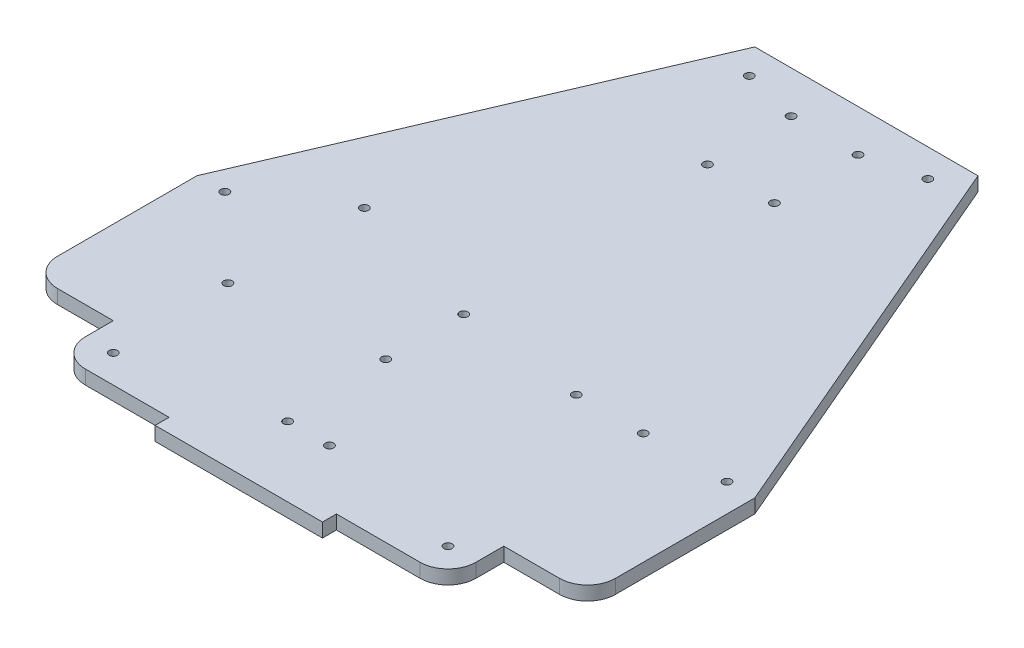
from build123d import *

# Parameters (mm, degrees)
BOSS_EXTRUDE1_DEPTH = 5
SKETCH3_R           = 1.5
CUT_EXTRUDE2_DEPTH  = 6
SKETCH6_R           = 1.5
CUT_EXTRUDE4_DEPTH  = 6
SKETCH8_R           = 1.5
CUT_EXTRUDE5_DEPTH  = 10
SKETCH9_R           = 1.5
CUT_EXTRUDE6_DEPTH  = 10


with BuildPart() as part:
    # Sketch1 → Boss-Extrude1 (new body)
    with BuildSketch(Plane(origin=(0, 0, 0), x_dir=(1, 0, 0), z_dir=(0, 1, 0))):
        with BuildLine():
            Line((100, -40), (100, 10))
            Line((100, 10), (40, 150))
            Line((40, 150), (-40, 150))
            Line((-40, 150), (-100, 10))
            Line((-100, 10), (-100, -40))
            ThreePointArc((-100, -40), (-97.071067812, -47.071067812), (-90, -50))
            Line((-90, -50), (-70, -50))
            Line((-70, -50), (-70, -60))
            ThreePointArc((-70, -60), (-67.071067812, -67.071067812), (-60, -70))
            Line((-60, -70), (-30, -70))
            Line((-30, -70), (-30, -75))
            Line((-30, -75), (30, -75))
            Line((30, -75), (30, -70))
            Line((30, -70), (60, -70))
            ThreePointArc((60, -70), (67.071067812, -67.071067812), (70, -60))
            Line((70, -60), (70, -50))
            Line((70, -50), (90, -50))
            ThreePointArc((90, -50), (97.071067812, -47.071067812), (100, -40))
        make_face()
    extrude(amount=BOSS_EXTRUDE1_DEPTH)

    # Sketch3 → Cut-Extrude2 (cut, through all)
    with BuildSketch(Plane(origin=(0, 5, 0), x_dir=(1, 0, 0), z_dir=(0, 1, 0))):
        with Locations((-61.1, -17.8)):
            Circle(SKETCH3_R)
        with Locations((-9.2, -13.1)):
            Circle(SKETCH3_R)
        with Locations((-9.2, 14.8)):
            Circle(SKETCH3_R)
        with Locations((-60, 30)):
            Circle(SKETCH3_R)
    extrude(amount=-CUT_EXTRUDE2_DEPTH, mode=Mode.SUBTRACT)

    # Sketch6 → Cut-Extrude4 (cut, through all)
    with BuildSketch(Plane(origin=(0, 5, 0), x_dir=(1, 0, 0), z_dir=(0, 1, 0))):
        with Locations((12, 135)):
            Circle(SKETCH6_R)
        with Locations((-12, 135)):
            Circle(SKETCH6_R)
        with Locations((12, 105)):
            Circle(SKETCH6_R)
        with Locations((-12, 105)):
            Circle(SKETCH6_R)
    extrude(amount=-CUT_EXTRUDE4_DEPTH, mode=Mode.SUBTRACT)

    # Sketch8 → Cut-Extrude5 (cut)
    with BuildSketch(Plane(origin=(0, 5, 0), x_dir=(1, 0, 0), z_dir=(0, 1, 0))):
        with Locations((-90, 10)):
            Circle(SKETCH8_R)
        with Locations((-32, 140)):
            Circle(SKETCH8_R)
        with Locations((90, 10)):
            Circle(SKETCH8_R)
        with Locations((32, 140)):
            Circle(SKETCH8_R)
        with Locations((-60, -60)):
            Circle(SKETCH8_R)
        with Locations((60, -60)):
            Circle(SKETCH8_R)
        with Locations((-7.5, -50)):
            Circle(SKETCH8_R)
        with Locations((7.5, -50)):
            Circle(SKETCH8_R)
    extrude(amount=-CUT_EXTRUDE5_DEPTH, mode=Mode.SUBTRACT)

    # Sketch9 → Cut-Extrude6 (cut)
    with BuildSketch(Plane(origin=(0, 5, 0), x_dir=(1, 0, 0), z_dir=(0, 1, 0))):
        with Locations((60, 10)):
            Circle(SKETCH9_R)
        with Locations((36, 10)):
            Circle(SKETCH9_R)
    extrude(amount=-CUT_EXTRUDE6_DEPTH, mode=Mode.SUBTRACT)


solid = part.part
